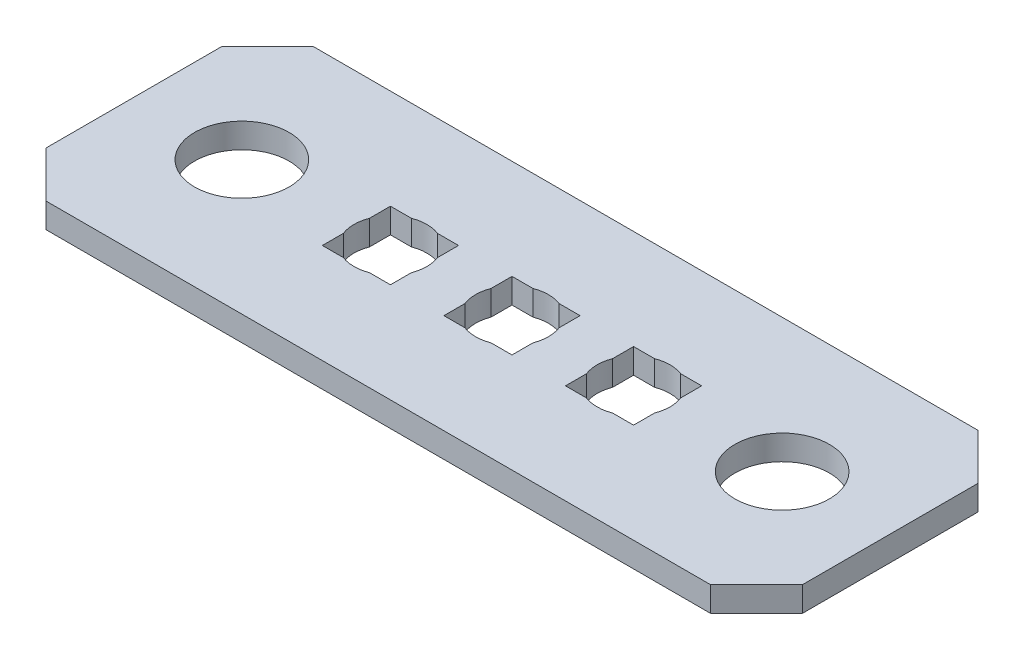
from build123d import *

# Parameters (mm, degrees)
SKETCH1_R           = 2.2225
SKETCH1_W           = 3.2004
SKETCH1_H           = 3.2004
BOSS_EXTRUDE1_DEPTH = 1.1684
SKETCH2_R           = 1.7145
CUT_EXTRUDE1_DEPTH  = 2.54


with BuildPart() as part:
    # Sketch1 → Boss-Extrude1 (new body)
    with BuildSketch(Plane.XZ):
        Polygon((33.401, -12.573), (35.56, -10.414), (35.56, -2.159), (33.401, 0), (2.159, 0), (0, -2.159), (0, -10.414), (2.159, -12.573), align=None)
        with Locations((5.08, -6.2865)):
            Circle(SKETCH1_R, mode=Mode.SUBTRACT)
        with Locations((30.48, -6.2865)):
            Circle(SKETCH1_R, mode=Mode.SUBTRACT)
        with Locations((23.495, -6.2865)):
            Rectangle(SKETCH1_W, SKETCH1_H, mode=Mode.SUBTRACT)
        with Locations((12.065, -6.2865)):
            Rectangle(SKETCH1_W, SKETCH1_H, mode=Mode.SUBTRACT)
        with Locations((17.78, -6.2865)):
            Rectangle(SKETCH1_W, SKETCH1_H, mode=Mode.SUBTRACT)
    extrude(amount=-BOSS_EXTRUDE1_DEPTH)

    # Sketch2 → Cut-Extrude1 (cut)
    with BuildSketch(Plane(origin=(0, 1.1684, 0), x_dir=(1, 0, 0), z_dir=(0, 1, 0))):
        with Locations((12.065, 6.2865)):
            Circle(SKETCH2_R)
        with Locations((17.78, 6.2865)):
            Circle(SKETCH2_R)
        with Locations((23.495, 6.2865)):
            Circle(SKETCH2_R)
    extrude(amount=-CUT_EXTRUDE1_DEPTH, mode=Mode.SUBTRACT)


solid = part.part
